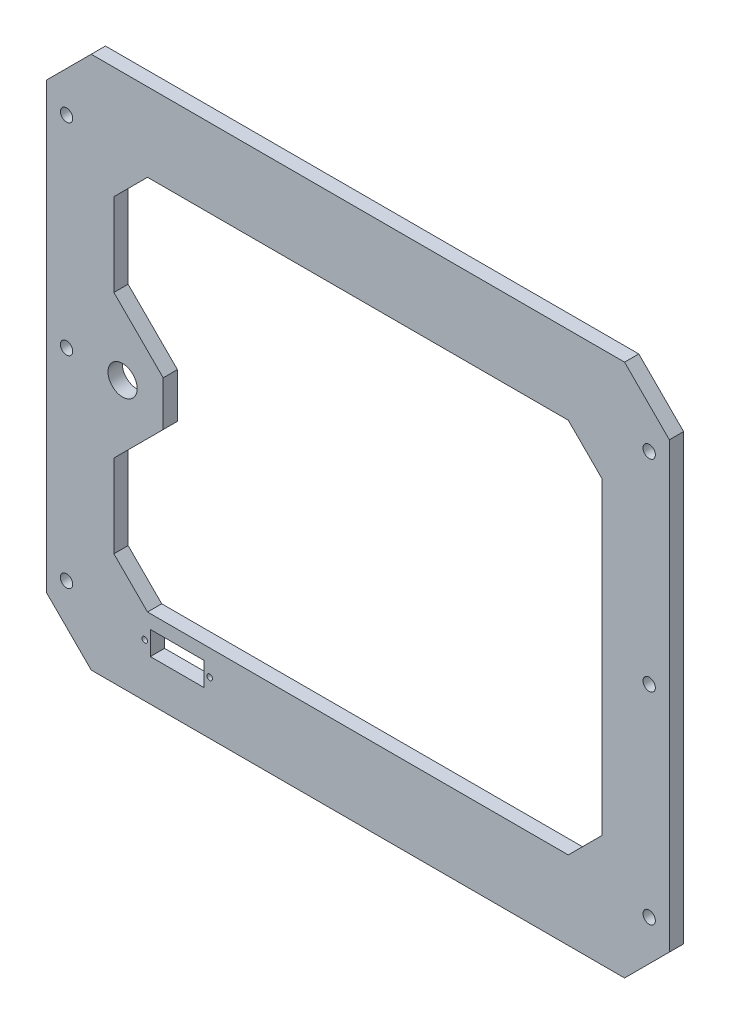
from build123d import *

# Parameters (mm, degrees)
SKETCH1_W           = 278
SKETCH1_H           = 238
BOSS_EXTRUDE1_DEPTH = 6.35
CHAMFER1_SIZE       = 20
SKETCH4_R           = 2.75
CUT_EXTRUDE2_DEPTH  = 76.2
SKETCH5_R           = 6.5
CUT_EXTRUDE3_DEPTH  = 10
SKETCH7_R           = 1.25
SKETCH7_W           = 24
SKETCH7_H           = 10.5
CUT_EXTRUDE4_DEPTH  = 7.35


with BuildPart() as part:
    # Sketch1 → Boss-Extrude1 (new body)
    with BuildSketch(Plane.XY):
        Rectangle(SKETCH1_W, SKETCH1_H)
    extrude(amount=BOSS_EXTRUDE1_DEPTH)

    # Chamfer1
    chamfer1_edges = [part.edges().sort_by_distance(p)[0] for p in [
        (-139, 119, 3.175),
        (139, 119, 3.175),
        (139, -119, 3.175),
        (-139, -119, 3.175),
    ]]
    chamfer(chamfer1_edges, length=CHAMFER1_SIZE)

    # Sketch4 → Cut-Extrude2 (cut)
    with BuildSketch(Plane.XY.offset(6.35)):
        with Locations((-130, 90)):
            Circle(SKETCH4_R)
        with Locations((-130, -90)):
            Circle(SKETCH4_R)
        with Locations((-130, 0)):
            Circle(SKETCH4_R)
        with Locations((130, -90)):
            Circle(SKETCH4_R)
        with Locations((130, 0)):
            Circle(SKETCH4_R)
        with Locations((130, 90)):
            Circle(SKETCH4_R)
    extrude(amount=-CUT_EXTRUDE2_DEPTH, mode=Mode.SUBTRACT)

    # Sketch5 → Cut-Extrude3 (cut)
    with BuildSketch(Plane.XY.offset(6.35)):
        with Locations((-105, 0)):
            Circle(SKETCH5_R)
        Polygon((93.875716073, -84), (-93.875716073, -84), (-108.875716073, -69), (-108.875716073, -32), (-86.875716073, -10), (-86.875716073, 10), (-108.875716073, 32), (-108.875716073, 69), (-93.875716073, 84), (93.875716073, 84), (108.875716073, 69), (108.875716073, -69), align=None)
    extrude(amount=-CUT_EXTRUDE3_DEPTH, mode=Mode.SUBTRACT)

    # Sketch7 → Cut-Extrude4 (cut, through all)
    with BuildSketch(Plane.XY.offset(6.35)):
        with Locations((-66.115841415, -95.342057099)):
            Circle(SKETCH7_R)
        with Locations((-95.115841415, -95.342057099)):
            Circle(SKETCH7_R)
        with Locations((-80.615841415, -95.342057099)):
            Rectangle(SKETCH7_W, SKETCH7_H)
    extrude(amount=-CUT_EXTRUDE4_DEPTH, mode=Mode.SUBTRACT)


solid = part.part
